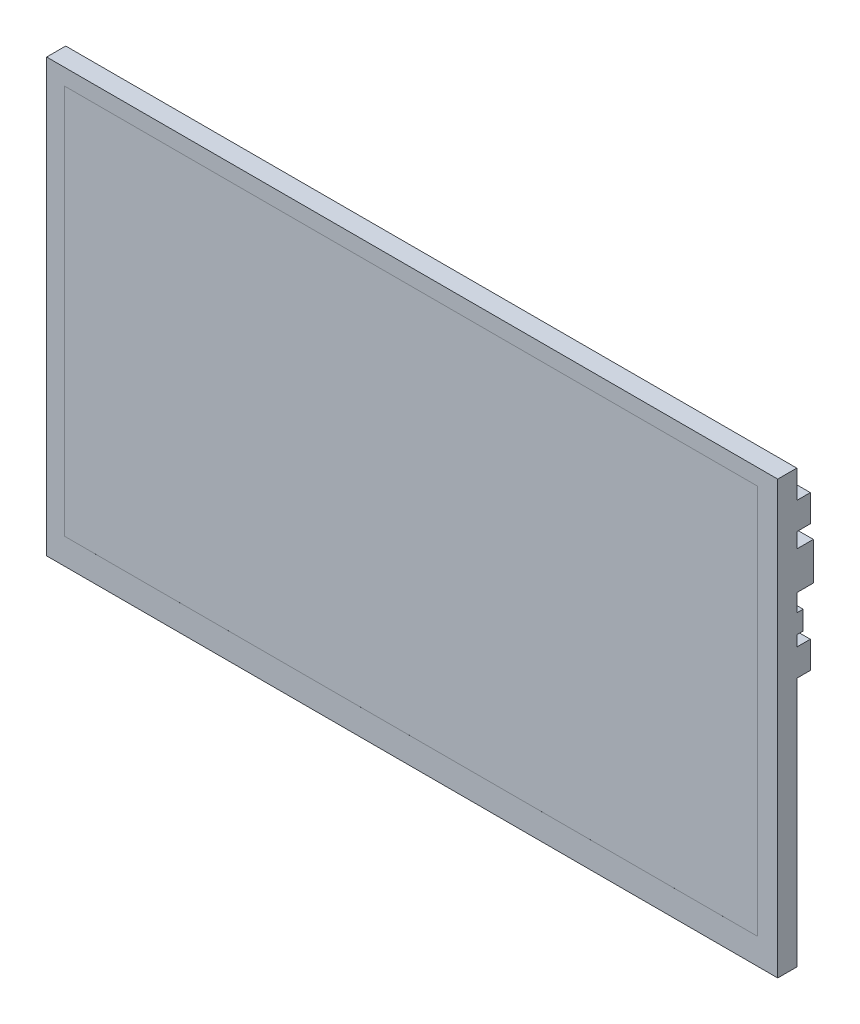
from build123d import *

# Parameters (mm, degrees)
SKETCH1_W           = 270.37
SKETCH1_H           = 159.79
BOSS_EXTRUDE1_DEPTH = 7.05
SKETCH2_W           = 256.32
SKETCH2_H           = 144.18
CUT_EXTRUDE1_DEPTH  = 0.001
SKETCH3_W           = 25
SKETCH3_H           = 10
BOSS_EXTRUDE3_DEPTH = 5
SKETCH3_3_W         = 25
SKETCH3_3_H         = 14
BOSS_EXTRUDE4_DEPTH = 6.12
SKETCH3_4_W         = 25
SKETCH3_4_H         = 7
BOSS_EXTRUDE5_DEPTH = 2.35
SKETCH3_5_W         = 25
SKETCH3_5_H         = 10
BOSS_EXTRUDE6_DEPTH = 5


with BuildPart() as part:
    # Sketch1 → Boss-Extrude1 (new body)
    with BuildSketch(Plane.XY):
        Rectangle(SKETCH1_W, SKETCH1_H)
    extrude(amount=-BOSS_EXTRUDE1_DEPTH)

    # Sketch2 → Cut-Extrude1 (cut)
    with BuildSketch(Plane.XY):
        with Locations((-0.425, 1.805)):
            Rectangle(SKETCH2_W, SKETCH2_H)
    extrude(amount=-CUT_EXTRUDE1_DEPTH, mode=Mode.SUBTRACT)

    # Sketch3 → Boss-Extrude3 (add)
    with BuildSketch(Plane(origin=(0, 0, -7.05), x_dir=(-1, 0, 0), z_dir=(0, 0, -1))):
        with Locations((-122.685, 64.545)):
            Rectangle(SKETCH3_W, SKETCH3_H)
    extrude(amount=BOSS_EXTRUDE3_DEPTH)

    # Sketch3_3 → Boss-Extrude4 (add)
    with BuildSketch(Plane(origin=(0, 0, -7.05), x_dir=(-1, 0, 0), z_dir=(0, 0, -1))):
        with Locations((-122.685, 47.005)):
            Rectangle(SKETCH3_3_W, SKETCH3_3_H)
    extrude(amount=BOSS_EXTRUDE4_DEPTH)

    # Sketch3_4 → Boss-Extrude5 (add)
    with BuildSketch(Plane(origin=(0, 0, -7.05), x_dir=(-1, 0, 0), z_dir=(0, 0, -1))):
        with Locations((-122.685, 30.025)):
            Rectangle(SKETCH3_4_W, SKETCH3_4_H)
    extrude(amount=BOSS_EXTRUDE5_DEPTH)

    # Sketch3_5 → Boss-Extrude6 (add)
    with BuildSketch(Plane(origin=(0, 0, -7.05), x_dir=(-1, 0, 0), z_dir=(0, 0, -1))):
        with Locations((-122.685, 17.585)):
            Rectangle(SKETCH3_5_W, SKETCH3_5_H)
    extrude(amount=BOSS_EXTRUDE6_DEPTH)


solid = part.part
